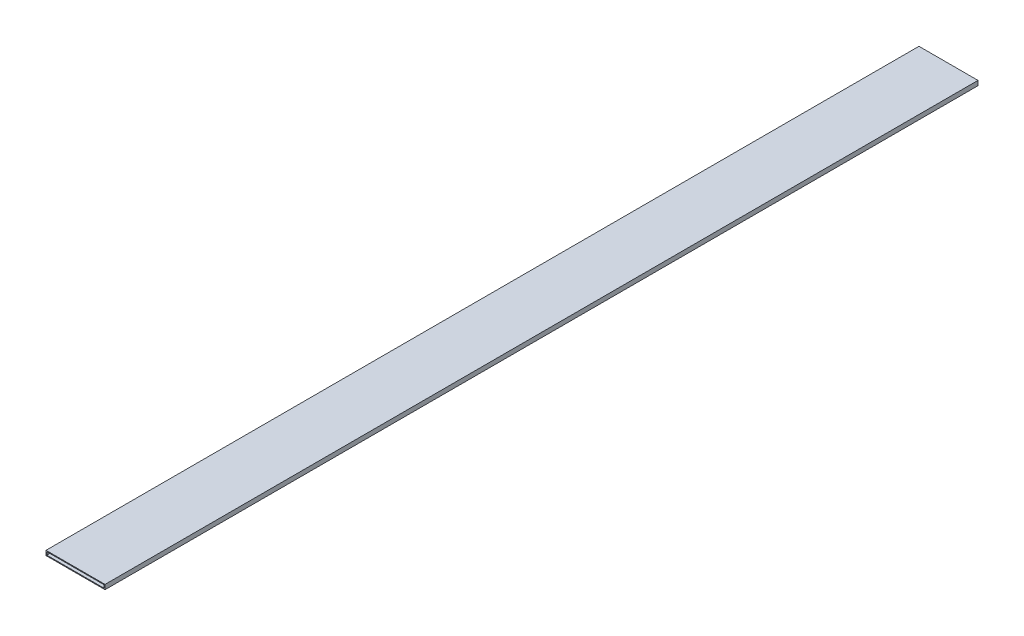
from build123d import *

# Parameters (mm, degrees)
SKETCH1_W           = 23
SKETCH1_H           = 1.8
SKETCH1_W_2         = 22.36
SKETCH1_H_2         = 1.16
BOSS_EXTRUDE1_DEPTH = 340


with BuildPart() as part:
    # Sketch1 → Boss-Extrude1 (new body)
    with BuildSketch(Plane.XY):
        with Locations((9.863636364, -0.314090909)):
            Rectangle(SKETCH1_W, SKETCH1_H)
        with Locations((9.863636364, -0.314090909)):
            Rectangle(SKETCH1_W_2, SKETCH1_H_2, mode=Mode.SUBTRACT)
    extrude(amount=BOSS_EXTRUDE1_DEPTH)


solid = part.part
